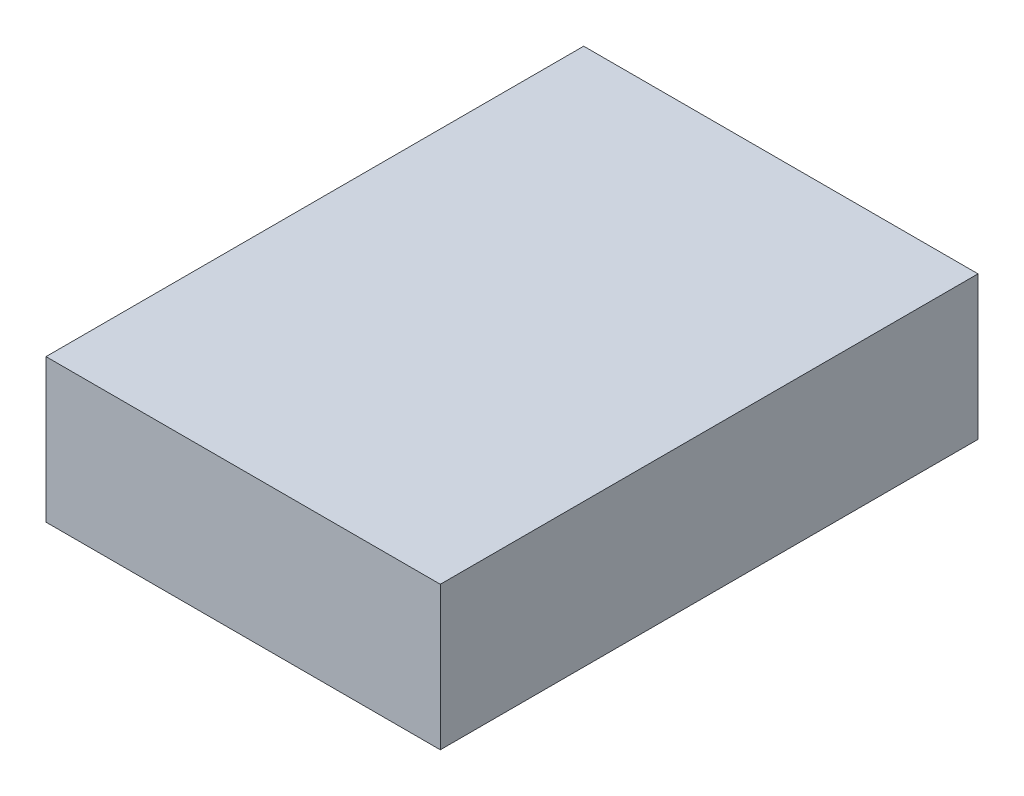
from build123d import *

# Parameters (mm, degrees)
SKETCH1_W           = 69.85
SKETCH1_H           = 95.25
BOSS_EXTRUDE1_DEPTH = 25.4


with BuildPart() as part:
    # Sketch1 → Boss-Extrude1 (new body)
    with BuildSketch(Plane(origin=(0, 0, 0), x_dir=(1, 0, 0), z_dir=(0, 1, 0))):
        with Locations((34.925, 47.625)):
            Rectangle(SKETCH1_W, SKETCH1_H)
    extrude(amount=BOSS_EXTRUDE1_DEPTH)


solid = part.part
